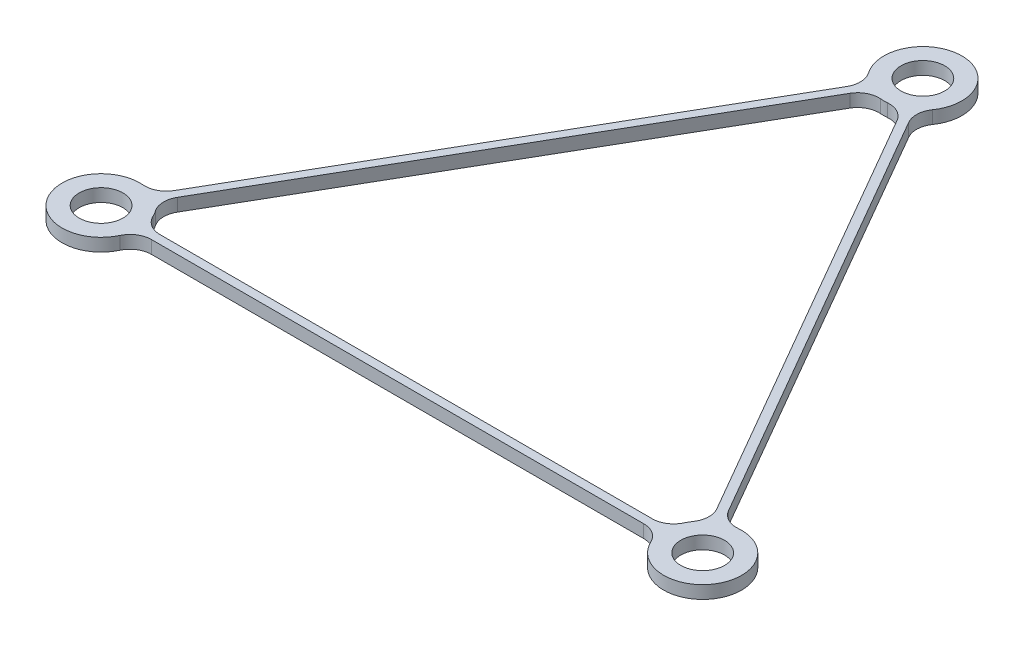
from build123d import *

# Parameters (mm, degrees)
SKETCH2_R        = 2.55
MAIN_SHAPE_DEPTH = 0.75
OUTSIDE_FILLET_R = 2.5
INSIDE_FILLET_R  = 2.5


with BuildPart() as part:
    # Sketch2 → main_shape (new body, symmetric)
    with BuildSketch(Plane(origin=(0, 0, 0), x_dir=(1, 0, 0), z_dir=(0, 1, 0))):
        with BuildLine():
            Line((-33.271790687, -16.098443032), (-2.694234717, 36.86343748))
            ThreePointArc((-2.694234717, 36.86343748), (0, 45.079988897), (2.694234717, 36.86343748))
            Line((2.694234717, 36.86343748), (33.271790687, -16.098443032))
            ThreePointArc((33.271790687, -16.098443032), (39.040415587, -22.539994449), (30.57755597, -20.764994449))
            Line((30.57755597, -20.764994449), (-30.57755597, -20.764994449))
            ThreePointArc((-30.57755597, -20.764994449), (-39.040415587, -22.539994449), (-33.271790687, -16.098443032))
        make_face()
        with Locations((0, 40.529988897)):
            Circle(SKETCH2_R, mode=Mode.SUBTRACT)
        with Locations((35.1, -20.264994449)):
            Circle(SKETCH2_R, mode=Mode.SUBTRACT)
        with Locations((-35.1, -20.264994449)):
            Circle(SKETCH2_R, mode=Mode.SUBTRACT)
        with BuildLine():
            Line((-30.57755597, -19.764994449), (30.57755597, -19.764994449))
            ThreePointArc((30.57755597, -19.764994449), (31.159584413, -17.989994449), (32.405765283, -16.598443032))
            Line((32.405765283, -16.598443032), (1.828209313, 36.36343748))
            ThreePointArc((1.828209313, 36.36343748), (0, 35.979988897), (-1.828209313, 36.36343748))
            Line((-1.828209313, 36.36343748), (-32.405765283, -16.598443032))
            ThreePointArc((-32.405765283, -16.598443032), (-31.159584413, -17.989994449), (-30.57755597, -19.764994449))
        make_face(mode=Mode.SUBTRACT)
    extrude(amount=MAIN_SHAPE_DEPTH, both=True)

    # outside_fillet
    outside_fillet_edges = [part.edges().sort_by_distance(p)[0] for p in [
        (-33.271790687, 0, 16.098443032),
        (-2.694234717, 0, -36.86343748),
        (2.694234717, 0, -36.86343748),
        (33.271790687, 0, 16.098443032),
        (30.57755597, 0, 20.764994449),
        (-30.57755597, 0, 20.764994449),
    ]]
    fillet(outside_fillet_edges, radius=OUTSIDE_FILLET_R)

    # inside_fillet
    inside_fillet_edges = [part.edges().sort_by_distance(p)[0] for p in [
        (1.828209313, 0, -36.36343748),
        (-1.828209313, 0, -36.36343748),
        (-32.405765283, 0, 16.598443032),
        (-30.57755597, 0, 19.764994449),
        (30.57755597, 0, 19.764994449),
        (32.405765283, 0, 16.598443032),
    ]]
    fillet(inside_fillet_edges, radius=INSIDE_FILLET_R)


solid = part.part
